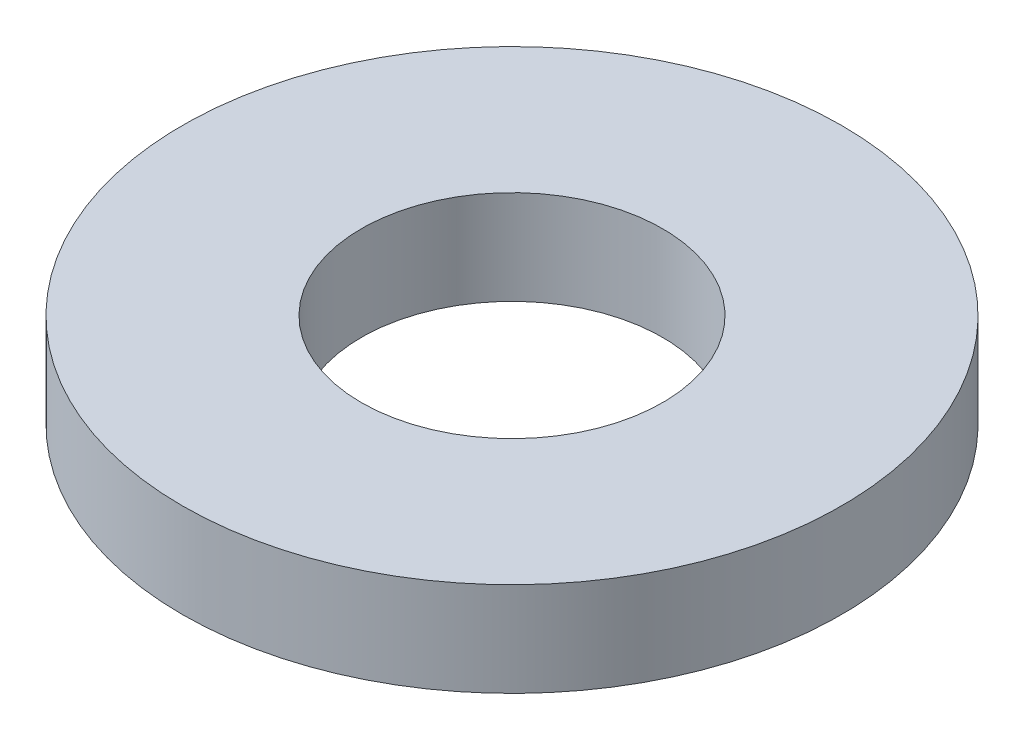
from build123d import *

# Parameters (mm, degrees)
SKETCH3_R           = 3.5
SKETCH3_R_2         = 1.6
BOSS_EXTRUDE1_DEPTH = 1


with BuildPart() as part:
    # Sketch3 → Boss-Extrude1 (new body)
    with BuildSketch(Plane(origin=(0, 0, 0), x_dir=(1, 0, 0), z_dir=(0, 1, 0))):
        Circle(SKETCH3_R)
        Circle(SKETCH3_R_2, mode=Mode.SUBTRACT)
    extrude(amount=BOSS_EXTRUDE1_DEPTH)


solid = part.part
